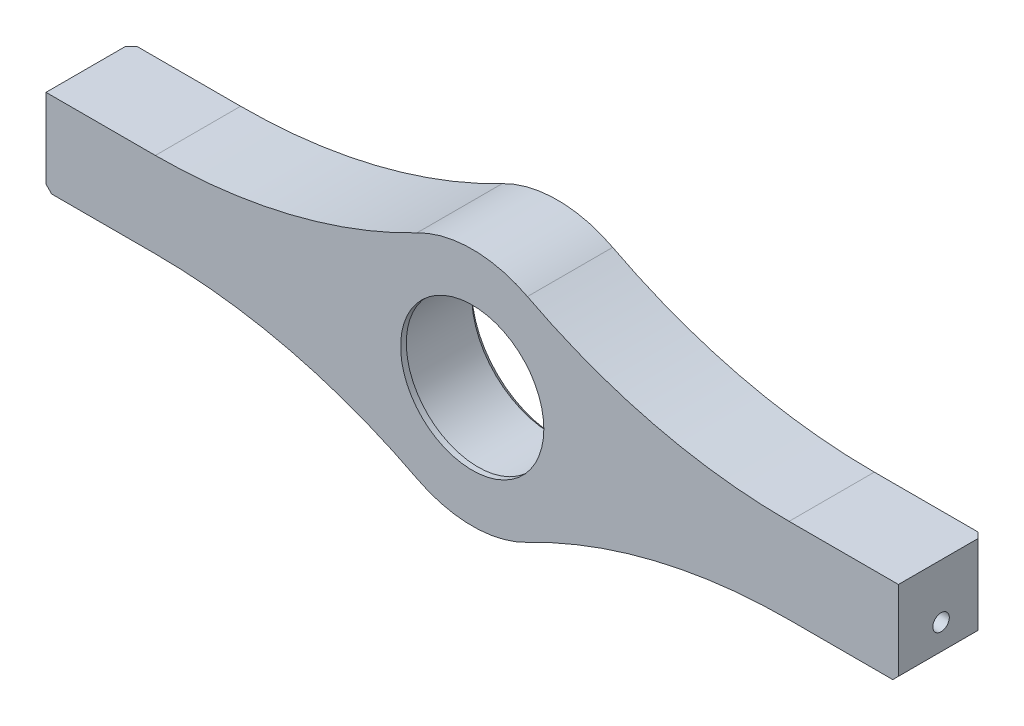
from build123d import *

# Parameters (mm, degrees)
SKIZZE1_R                       = 14.1
AUFSATZ_LINEAR_AUSTRAGEN1_DEPTH = 15
VERRUNDUNG1_R                   = 100
SKIZZE2_R                       = 1.4
SCHNITT_LINEAR_AUSTRAGEN1_DEPTH = 10
SKIZZE3_R                       = 1.45
SCHNITT_LINEAR_AUSTRAGEN2_DEPTH = 10
SKIZZE6_R                       = 14.1
SKIZZE6_R_2                     = 12.6
AUFSATZ_LINEAR_AUSTRAGEN3_DEPTH = 1
FASE1_SIZE                      = 1
FASE2_SIZE                      = 1


with BuildPart() as part:
    # Skizze1 → Aufsatz-Linear austragen1 (new body)
    with BuildSketch(Plane.XY):
        with BuildLine():
            Line((19.722068857, 7.5), (75, 7.5))
            Line((75, 7.5), (75, -7.5))
            Line((75, -7.5), (19.722068857, -7.5))
            ThreePointArc((19.722068857, -7.5), (0, -21.1), (-19.722068857, -7.5))
            Line((-19.722068857, -7.5), (-75, -7.5))
            Line((-75, -7.5), (-75, 7.5))
            Line((-75, 7.5), (-19.722068857, 7.5))
            ThreePointArc((-19.722068857, 7.5), (0, 21.1), (19.722068857, 7.5))
        make_face()
        Circle(SKIZZE1_R, mode=Mode.SUBTRACT)
    extrude(amount=AUFSATZ_LINEAR_AUSTRAGEN1_DEPTH)

    # Verrundung1
    verrundung1_edges = [part.edges().sort_by_distance(p)[0] for p in [
        (19.722068857, -7.5, 7.5),
        (-19.722068857, -7.5, 7.5),
        (-19.722068857, 7.5, 7.5),
        (19.722068857, 7.5, 7.5),
    ]]
    fillet(verrundung1_edges, radius=VERRUNDUNG1_R)

    # Skizze2 → Schnitt-Linear austragen1 (cut)
    with BuildSketch(Plane(origin=(0, 0, 0), x_dir=(-1, 0, 0), z_dir=(0, 0, -1))):
        with Locations((-67.5, 2)):
            Circle(SKIZZE2_R)
        with Locations((67.5, 2)):
            Circle(SKIZZE2_R)
    extrude(amount=-SCHNITT_LINEAR_AUSTRAGEN1_DEPTH, mode=Mode.SUBTRACT)

    # Skizze3 → Schnitt-Linear austragen2 (cut)
    with BuildSketch(Plane(origin=(75, 0, 0), x_dir=(0, 0, -1), z_dir=(1, 0, 0))):
        with Locations((-7.5, -2)):
            Circle(SKIZZE3_R)
    schnitt_linear_austragen2 = extrude(amount=-SCHNITT_LINEAR_AUSTRAGEN2_DEPTH, mode=Mode.SUBTRACT)

    # Spiegeln1: Schnitt-Linear austragen2 across plane
    add(schnitt_linear_austragen2.mirror(Plane(origin=(0, 0, 0), x_dir=(0, 0, 1), z_dir=(1, 0, 0))), mode=Mode.SUBTRACT)

    # Skizze6 → Aufsatz-Linear austragen3 (add)
    with BuildSketch(Plane.XY.offset(15)):
        Circle(SKIZZE6_R)
        Circle(SKIZZE6_R_2, mode=Mode.SUBTRACT)
    extrude(amount=-AUFSATZ_LINEAR_AUSTRAGEN3_DEPTH)

    # Fase1
    fase1_edges = [part.edges().sort_by_distance(p)[0] for p in [
        (-14.1, 0, 0),
    ]]
    chamfer(fase1_edges, length=FASE1_SIZE)

    # Fase2
    fase2_edges = [part.edges().sort_by_distance(p)[0] for p in [
        (75, 0, 0),
        (75, -7.5, 7.5),
        (-75, -7.5, 7.5),
        (-75, 0, 0),
    ]]
    chamfer(fase2_edges, length=FASE2_SIZE)


solid = part.part
